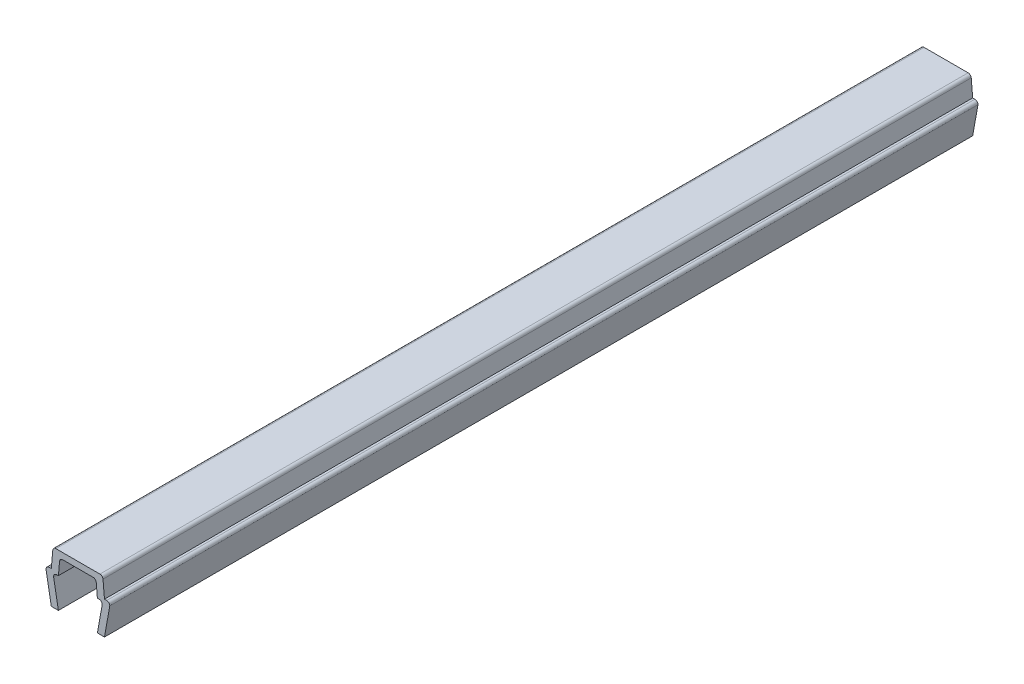
from build123d import *

# Parameters (mm, degrees)
BOSS_EXTRUDE1_DEPTH = 49


with BuildPart() as part:
    # Sketch1 → Boss-Extrude1 (new body, symmetric)
    with BuildSketch(Plane.XY):
        with BuildLine():
            Line((-3.6, 3.35), (-3, 0))
            Line((-3, 0), (-2.2, 0))
            Line((-2.2, 0), (-2.735217071, 2.988295315))
            ThreePointArc((-2.735217071, 2.988295315), (-2.659117427, 3.274614514), (-2.390699246, 3.4))
            Line((-2.390699246, 3.4), (-2.2, 3.4))
            Line((-2.2, 3.4), (-2.070472639, 4.88050451))
            ThreePointArc((-2.070472639, 4.88050451), (-1.958261067, 5.108047068), (-1.721804495, 5.2))
            Line((-1.721804495, 5.2), (1.721804495, 5.2))
            ThreePointArc((1.721804495, 5.2), (1.958261067, 5.108047068), (2.070472639, 4.88050451))
            Line((2.070472639, 4.88050451), (2.2, 3.4))
            Line((2.2, 3.4), (2.390699246, 3.4))
            ThreePointArc((2.390699246, 3.4), (2.659117427, 3.274614514), (2.735217071, 2.988295315))
            Line((2.735217071, 2.988295315), (2.2, 0))
            Line((2.2, 0), (3, 0))
            Line((3, 0), (3.6, 3.35))
            ThreePointArc((3.6, 3.35), (3.497487373, 3.597487373), (3.25, 3.7))
            Line((3.25, 3.7), (3, 3.7))
            Line((3, 3.7), (2.835477174, 5.58050451))
            ThreePointArc((2.835477174, 5.58050451), (2.723265602, 5.808047068), (2.486809029, 5.9))
            Line((2.486809029, 5.9), (-2.486809029, 5.9))
            ThreePointArc((-2.486809029, 5.9), (-2.723265602, 5.808047068), (-2.835477174, 5.58050451))
            Line((-2.835477174, 5.58050451), (-3, 3.7))
            Line((-3, 3.7), (-3.25, 3.7))
            ThreePointArc((-3.25, 3.7), (-3.497487373, 3.597487373), (-3.6, 3.35))
        make_face()
    extrude(amount=BOSS_EXTRUDE1_DEPTH, both=True)


solid = part.part
